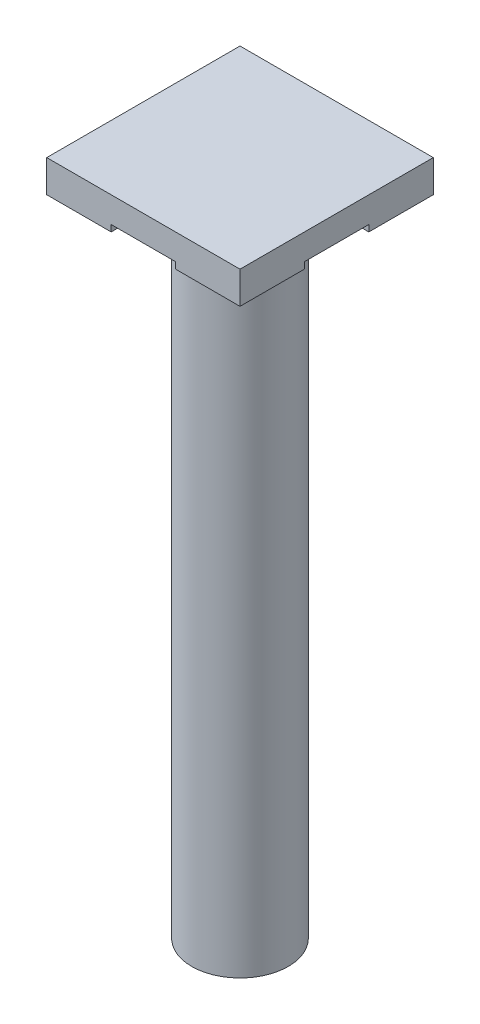
from build123d import *

# Parameters (mm, degrees)
SKETCH1_R           = 19.05
BOSS_EXTRUDE1_DEPTH = 254
SKETCH5_W           = 76.2
SKETCH5_H           = 76.2
BOSS_EXTRUDE3_DEPTH = 12.7
SKETCH6_W           = 8.89
SKETCH6_H           = 25.4
SKETCH6_W_2         = 25.4
SKETCH6_H_2         = 8.89
CUT_EXTRUDE1_DEPTH  = 2.54


with BuildPart() as part:
    # Sketch1 → Boss-Extrude1 (new body)
    with BuildSketch(Plane(origin=(0, 0, 0), x_dir=(1, 0, 0), z_dir=(0, 1, 0))):
        Circle(SKETCH1_R)
    extrude(amount=BOSS_EXTRUDE1_DEPTH)

    # Sketch5 → Boss-Extrude3 (add)
    with BuildSketch(Plane(origin=(0, 254, 0), x_dir=(1, 0, 0), z_dir=(0, 1, 0))):
        Rectangle(SKETCH5_W, SKETCH5_H)
    extrude(amount=BOSS_EXTRUDE3_DEPTH)

    # Sketch6 → Cut-Extrude1 (cut)
    with BuildSketch(Plane.XZ.offset(-254)):
        with Locations((-33.655, 0)):
            Rectangle(SKETCH6_W, SKETCH6_H)
        with Locations((0, 33.655)):
            Rectangle(SKETCH6_W_2, SKETCH6_H_2)
        with Locations((33.655, 0)):
            Rectangle(SKETCH6_W, SKETCH6_H)
        with Locations((0, -33.655)):
            Rectangle(SKETCH6_W_2, SKETCH6_H_2)
    extrude(amount=-CUT_EXTRUDE1_DEPTH, mode=Mode.SUBTRACT)


solid = part.part
